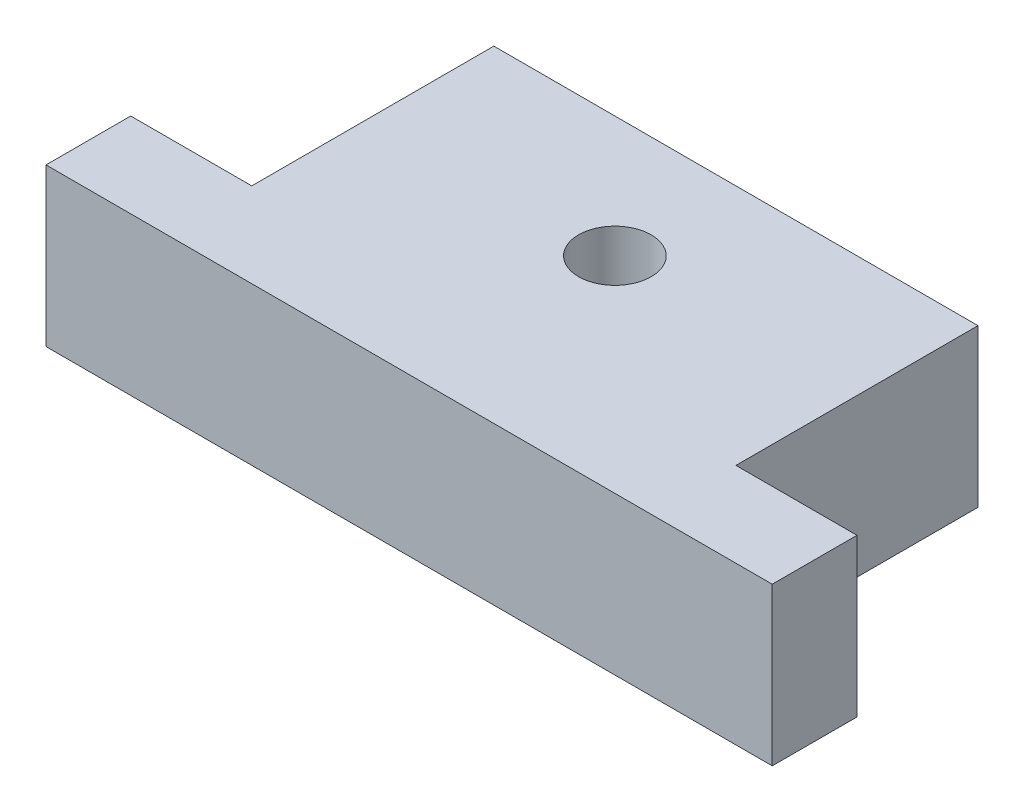
from build123d import *

# Parameters (mm, degrees)
SKETCH1_R           = 3
BOSS_EXTRUDE1_DEPTH = 13


with BuildPart() as part:
    # Sketch1 → Boss-Extrude1 (new body)
    with BuildSketch(Plane(origin=(0, 0, 0), x_dir=(1, 0, 0), z_dir=(0, 1, 0))):
        Polygon((-23.436385423, 11.790780002), (36.563614577, 11.790780002), (36.563614577, 18.790780002), (26.563614577, 18.790780002), (26.563614577, 38.790780002), (-13.436385423, 38.790780002), (-13.436385423, 18.790780002), (-23.436385423, 18.790780002), align=None)
        with Locations((6.563614577, 28.790780002)):
            Circle(SKETCH1_R, mode=Mode.SUBTRACT)
    extrude(amount=BOSS_EXTRUDE1_DEPTH)


solid = part.part
